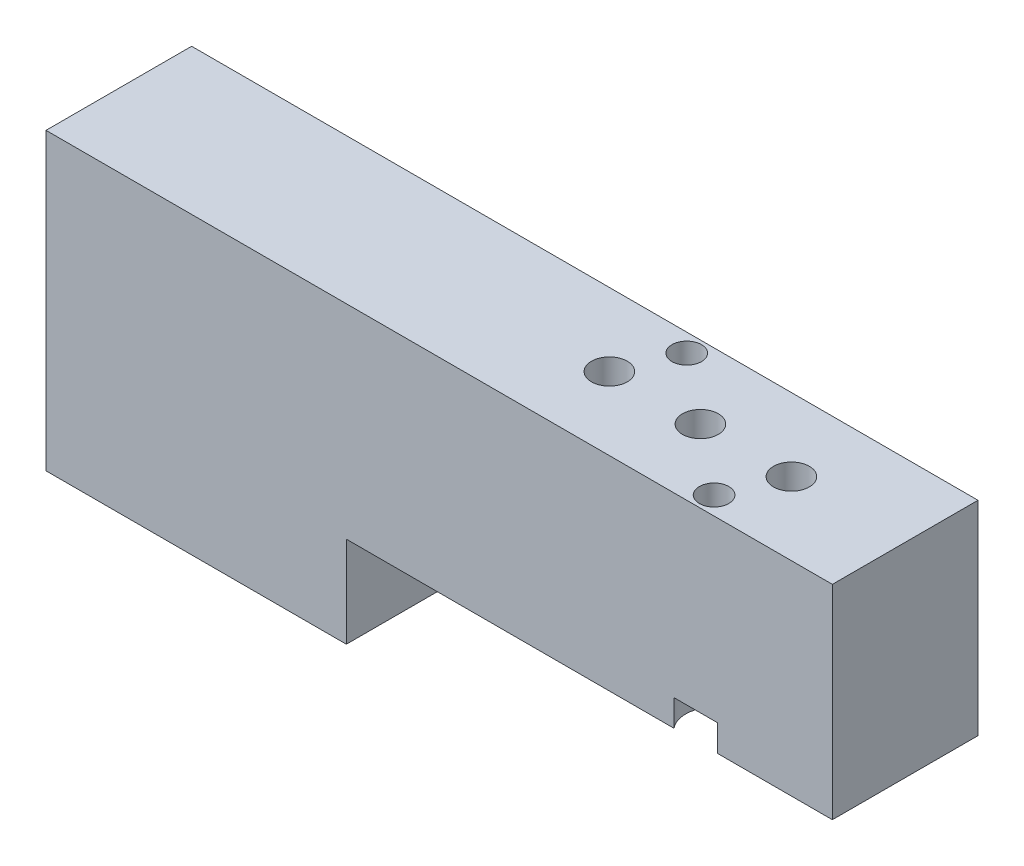
from build123d import *

# Parameters (mm, degrees)
SKETCH1_W                                      = 54.864
SKETCH1_H                                      = 14.224
BASE_EXTRUDE_DEPTH                             = 10.16
SKETCH2_W                                      = 20.955
SKETCH2_H                                      = 10.16
BOSS_EXTRUDE1_DEPTH                            = 6.35
M3X0_5_TAPPED_HOLE1_D                          = 2.5
M3X0_5_TAPPED_HOLE1_DEPTH                      = 7.499985
M3X0_5_TAPPED_HOLE1_TIP                        = 0.751075774
CBORE_FOR_1_SOCKET_HEAD_CAP_SCREW1_D           = 2.0574
CBORE_FOR_1_SOCKET_HEAD_CAP_SCREW1_DEPTH       = 22.86
CBORE_FOR_1_SOCKET_HEAD_CAP_SCREW1_CBORE_D     = 3.97002
CBORE_FOR_1_SOCKET_HEAD_CAP_SCREW1_CBORE_DEPTH = 1.8542
CBORE_FOR_1_SOCKET_HEAD_CAP_SCREW1_TIP         = 0.618105319
M3X0_5_TAPPED_HOLE2_D                          = 2.5
M3X0_5_TAPPED_HOLE2_DEPTH                      = 7.5000104
M3X0_5_TAPPED_HOLE2_TIP                        = 0.751075774


with BuildPart() as part:
    # Sketch1 → Base-Extrude (new body)
    with BuildSketch(Plane.XY):
        with Locations((27.432, 7.112)):
            Rectangle(SKETCH1_W, SKETCH1_H)
    extrude(amount=-BASE_EXTRUDE_DEPTH)

    # Sketch2 → Boss-Extrude1 (add)
    with BuildSketch(Plane.XZ):
        with Locations((10.4775, -5.08)):
            Rectangle(SKETCH2_W, SKETCH2_H)
    extrude(amount=BOSS_EXTRUDE1_DEPTH)

    # M3x0.5 Tapped Hole1
    with Locations(Plane(origin=(0, 14.224, 0), x_dir=(-1, 0, 0), z_dir=(0, 1, 0))):
        with Locations((-46.9265, -5.08), (-40.5765, -5.08), (-34.2265, -5.08)):
            Hole(M3X0_5_TAPPED_HOLE1_D / 2, depth=M3X0_5_TAPPED_HOLE1_DEPTH)
            with Locations((0, 0, -(M3X0_5_TAPPED_HOLE1_DEPTH + M3X0_5_TAPPED_HOLE1_TIP / 2))):  # 118° drill point
                Cone(0, M3X0_5_TAPPED_HOLE1_D / 2, M3X0_5_TAPPED_HOLE1_TIP, mode=Mode.SUBTRACT)

    # CBORE for #1 Socket Head Cap Screw1
    with Locations(Plane.XZ):
        with Locations((45.339, -1.27), (35.814, -8.89)):
            CounterBoreHole(CBORE_FOR_1_SOCKET_HEAD_CAP_SCREW1_D / 2, CBORE_FOR_1_SOCKET_HEAD_CAP_SCREW1_CBORE_D / 2, CBORE_FOR_1_SOCKET_HEAD_CAP_SCREW1_CBORE_DEPTH, depth=CBORE_FOR_1_SOCKET_HEAD_CAP_SCREW1_DEPTH)
            with Locations((0, 0, -(CBORE_FOR_1_SOCKET_HEAD_CAP_SCREW1_DEPTH + CBORE_FOR_1_SOCKET_HEAD_CAP_SCREW1_TIP / 2))):  # 118° drill point
                Cone(0, CBORE_FOR_1_SOCKET_HEAD_CAP_SCREW1_D / 2, CBORE_FOR_1_SOCKET_HEAD_CAP_SCREW1_TIP, mode=Mode.SUBTRACT)

    # M3x0.5 Tapped Hole2
    with Locations(Plane.XZ):
        with Locations((43.7642, -6.985), (37.4142, -3.175)):
            Hole(M3X0_5_TAPPED_HOLE2_D / 2, depth=M3X0_5_TAPPED_HOLE2_DEPTH)
            with Locations((0, 0, -(M3X0_5_TAPPED_HOLE2_DEPTH + M3X0_5_TAPPED_HOLE2_TIP / 2))):  # 118° drill point
                Cone(0, M3X0_5_TAPPED_HOLE2_D / 2, M3X0_5_TAPPED_HOLE2_TIP, mode=Mode.SUBTRACT)


solid = part.part
